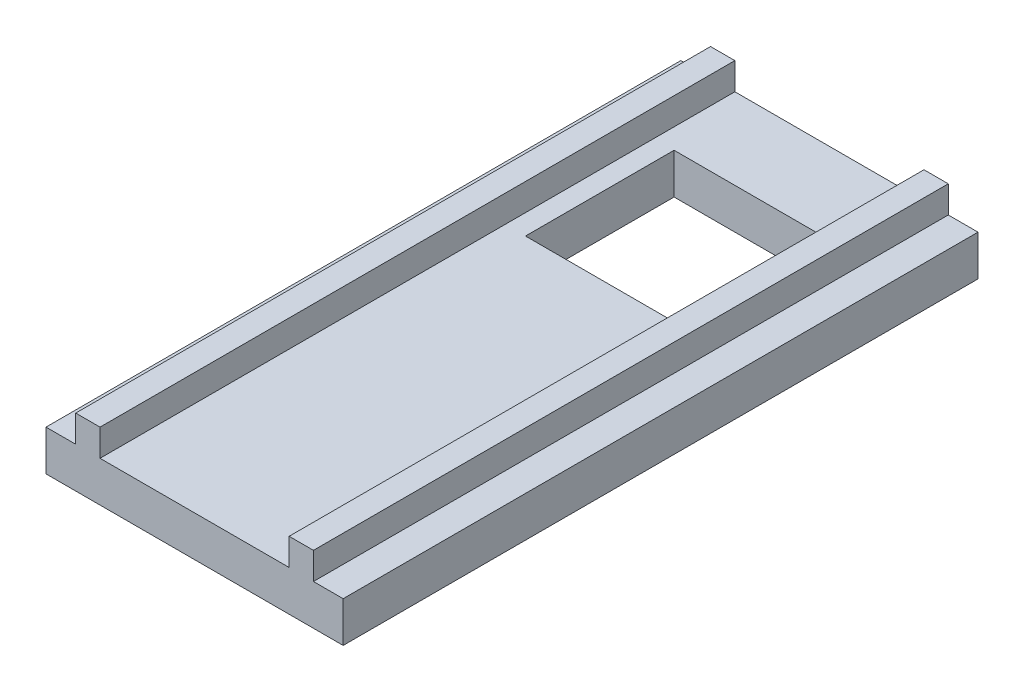
from build123d import *

# Parameters (mm, degrees)
SKETCH1_W           = 22
SKETCH1_H           = 47
SKETCH1_W_2         = 11
SKETCH1_H_2         = 11
BOSS_EXTRUDE_DEPTH  = 3
SKETCH5_W           = 1.8
SKETCH5_H           = 47
BOSS_EXTRUDE1_DEPTH = 2


with BuildPart() as part:
    # Sketch1 → Boss-Extrude (new body)
    with BuildSketch(Plane(origin=(0, 0, 0), x_dir=(1, 0, 0), z_dir=(0, 1, 0))):
        Rectangle(SKETCH1_W, SKETCH1_H)
        with Locations((0, 12)):
            Rectangle(SKETCH1_W_2, SKETCH1_H_2, mode=Mode.SUBTRACT)
    extrude(amount=BOSS_EXTRUDE_DEPTH)

    # Sketch5 → Boss-Extrude1 (add)
    with BuildSketch(Plane(origin=(0, 3, 0), x_dir=(1, 0, 0), z_dir=(0, 1, 0))):
        with Locations((-7.9, 0)):
            Rectangle(SKETCH5_W, SKETCH5_H)
        with Locations((7.9, 0)):
            Rectangle(SKETCH5_W, SKETCH5_H)
    extrude(amount=BOSS_EXTRUDE1_DEPTH)


solid = part.part
